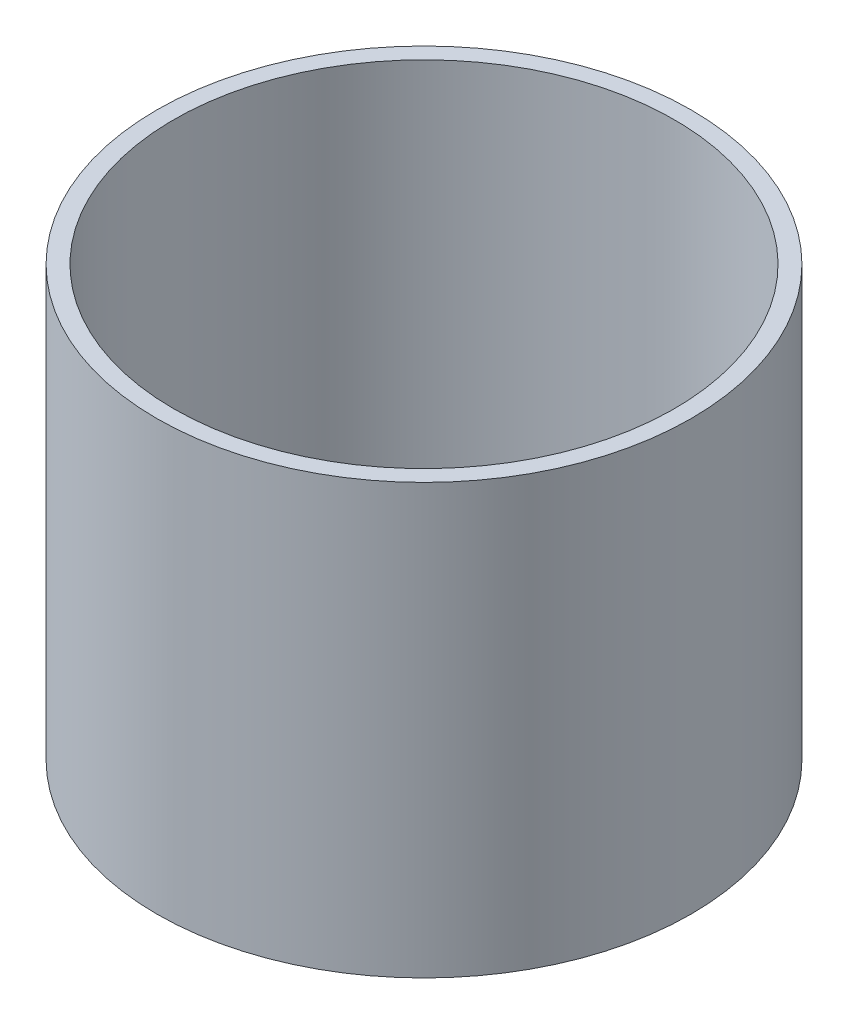
from build123d import *

# Parameters (mm, degrees)
SKETCH1_R           = 47.449994
SKETCH1_R_2         = 44.45
BOSS_EXTRUDE1_DEPTH = 76.2


with BuildPart() as part:
    # Sketch1 → Boss-Extrude1 (new body)
    with BuildSketch(Plane(origin=(0, 0, 0), x_dir=(1, 0, 0), z_dir=(0, 1, 0))):
        Circle(SKETCH1_R)
        Circle(SKETCH1_R_2, mode=Mode.SUBTRACT)
    extrude(amount=BOSS_EXTRUDE1_DEPTH)


solid = part.part
